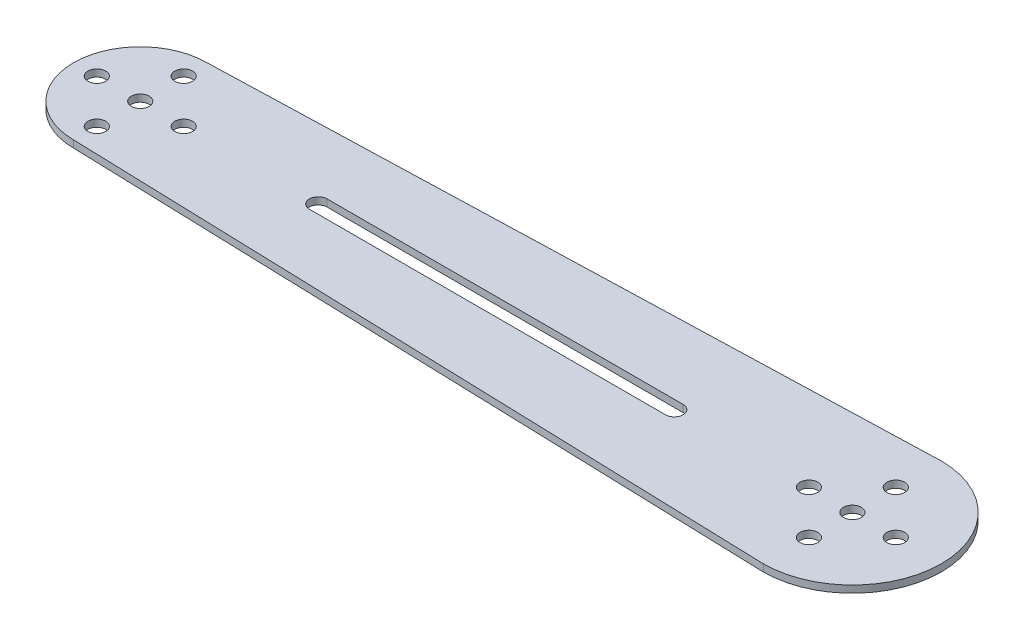
from build123d import *

# Parameters (mm, degrees)
BOSS_EXTRUDE1_DEPTH       = 2
F_5_0MM_DOWEL_HOLE1_D     = 5
F_5_0MM_DOWEL_HOLE1_DEPTH = 2
CUT_EXTRUDE1_REACH        = 4
SKETCH4_R                 = 2.5
CUT_EXTRUDE2_REACH        = 4


with BuildPart() as part:
    # Sketch2 → Boss-Extrude1 (new body)
    with BuildSketch(Plane(origin=(0, 0, 0), x_dir=(1, 0, 0), z_dir=(0, 1, 0))):
        with BuildLine():
            Line((100, 25), (-100, 18.75))
            ThreePointArc((-100, 18.75), (-118.75, 0), (-100, -18.75))
            Line((-100, -18.75), (100, -25))
            ThreePointArc((100, -25), (125, 0), (100, 25))
        make_face()
    extrude(amount=BOSS_EXTRUDE1_DEPTH)

    # Ø5.0mm Dowel Hole1
    with Locations(Plane(origin=(0, 2, 0), x_dir=(1, 0, 0), z_dir=(0, 1, 0))):
        with Locations((100, 0), (-100, 0)):
            Hole(F_5_0MM_DOWEL_HOLE1_D / 2, depth=F_5_0MM_DOWEL_HOLE1_DEPTH)

    # Sketch4 → Cut-Extrude1 (cut, up to next)
    with BuildSketch(Plane(origin=(0, 2, 0), x_dir=(1, 0, 0), z_dir=(0, 1, 0)), mode=Mode.PRIVATE) as cut_extrude1_sk1:
        with Locations((100, 12.2)):
            Circle(SKETCH4_R)
    cut_extrude1_tool1 = extrude(cut_extrude1_sk1.sketch, amount=-CUT_EXTRUDE1_REACH, mode=Mode.PRIVATE) & part.part
    add(cut_extrude1_tool1.solids().sort_by_distance((100, 2, -12.2))[0], mode=Mode.SUBTRACT)
    # Sketch4 → Cut-Extrude1 (cut, up to next)
    with BuildSketch(Plane(origin=(0, 2, 0), x_dir=(1, 0, 0), z_dir=(0, 1, 0)), mode=Mode.PRIVATE) as cut_extrude1_sk2:
        with Locations((100, -12.2)):
            Circle(SKETCH4_R)
    cut_extrude1_tool2 = extrude(cut_extrude1_sk2.sketch, amount=-CUT_EXTRUDE1_REACH, mode=Mode.PRIVATE) & part.part
    add(cut_extrude1_tool2.solids().sort_by_distance((100, 2, 12.2))[0], mode=Mode.SUBTRACT)
    # Sketch4 → Cut-Extrude1 (cut, up to next)
    with BuildSketch(Plane(origin=(0, 2, 0), x_dir=(1, 0, 0), z_dir=(0, 1, 0)), mode=Mode.PRIVATE) as cut_extrude1_sk3:
        with Locations((112.2, 0)):
            Circle(SKETCH4_R)
    cut_extrude1_tool3 = extrude(cut_extrude1_sk3.sketch, amount=-CUT_EXTRUDE1_REACH, mode=Mode.PRIVATE) & part.part
    add(cut_extrude1_tool3.solids().sort_by_distance((112.2, 2, 0))[0], mode=Mode.SUBTRACT)
    # Sketch4 → Cut-Extrude1 (cut, up to next)
    with BuildSketch(Plane(origin=(0, 2, 0), x_dir=(1, 0, 0), z_dir=(0, 1, 0)), mode=Mode.PRIVATE) as cut_extrude1_sk4:
        with Locations((87.8, 0)):
            Circle(SKETCH4_R)
    cut_extrude1_tool4 = extrude(cut_extrude1_sk4.sketch, amount=-CUT_EXTRUDE1_REACH, mode=Mode.PRIVATE) & part.part
    add(cut_extrude1_tool4.solids().sort_by_distance((87.8, 2, 0))[0], mode=Mode.SUBTRACT)
    # Sketch4 → Cut-Extrude1 (cut, up to next)
    with BuildSketch(Plane(origin=(0, 2, 0), x_dir=(1, 0, 0), z_dir=(0, 1, 0)), mode=Mode.PRIVATE) as cut_extrude1_sk5:
        with Locations((-100, 12.2)):
            Circle(SKETCH4_R)
    cut_extrude1_tool5 = extrude(cut_extrude1_sk5.sketch, amount=-CUT_EXTRUDE1_REACH, mode=Mode.PRIVATE) & part.part
    add(cut_extrude1_tool5.solids().sort_by_distance((-100, 2, -12.2))[0], mode=Mode.SUBTRACT)
    # Sketch4 → Cut-Extrude1 (cut, up to next)
    with BuildSketch(Plane(origin=(0, 2, 0), x_dir=(1, 0, 0), z_dir=(0, 1, 0)), mode=Mode.PRIVATE) as cut_extrude1_sk6:
        with Locations((-87.8, 0)):
            Circle(SKETCH4_R)
    cut_extrude1_tool6 = extrude(cut_extrude1_sk6.sketch, amount=-CUT_EXTRUDE1_REACH, mode=Mode.PRIVATE) & part.part
    add(cut_extrude1_tool6.solids().sort_by_distance((-87.8, 2, 0))[0], mode=Mode.SUBTRACT)
    # Sketch4 → Cut-Extrude1 (cut, up to next)
    with BuildSketch(Plane(origin=(0, 2, 0), x_dir=(1, 0, 0), z_dir=(0, 1, 0)), mode=Mode.PRIVATE) as cut_extrude1_sk7:
        with Locations((-112.2, 0)):
            Circle(SKETCH4_R)
    cut_extrude1_tool7 = extrude(cut_extrude1_sk7.sketch, amount=-CUT_EXTRUDE1_REACH, mode=Mode.PRIVATE) & part.part
    add(cut_extrude1_tool7.solids().sort_by_distance((-112.2, 2, 0))[0], mode=Mode.SUBTRACT)
    # Sketch4 → Cut-Extrude1 (cut, up to next)
    with BuildSketch(Plane(origin=(0, 2, 0), x_dir=(1, 0, 0), z_dir=(0, 1, 0)), mode=Mode.PRIVATE) as cut_extrude1_sk8:
        with Locations((-100, -12.2)):
            Circle(SKETCH4_R)
    cut_extrude1_tool8 = extrude(cut_extrude1_sk8.sketch, amount=-CUT_EXTRUDE1_REACH, mode=Mode.PRIVATE) & part.part
    add(cut_extrude1_tool8.solids().sort_by_distance((-100, 2, 12.2))[0], mode=Mode.SUBTRACT)

    # Sketch16 → Cut-Extrude2 (cut, up to next)
    with BuildSketch(Plane(origin=(0, 2, 0), x_dir=(1, 0, 0), z_dir=(0, 1, 0)), mode=Mode.PRIVATE) as cut_extrude2_sk1:
        with BuildLine():
            Line((-50, -2.5), (50, -2.5))
            ThreePointArc((50, -2.5), (52.5, 0), (50, 2.5))
            Line((50, 2.5), (-50, 2.5))
            ThreePointArc((-50, 2.5), (-52.5, 0), (-50, -2.5))
        make_face()
    cut_extrude2_tool1 = extrude(cut_extrude2_sk1.sketch, amount=-CUT_EXTRUDE2_REACH, mode=Mode.PRIVATE) & part.part
    add(cut_extrude2_tool1.solids().sort_by_distance((0, 2, 0))[0], mode=Mode.SUBTRACT)


solid = part.part
